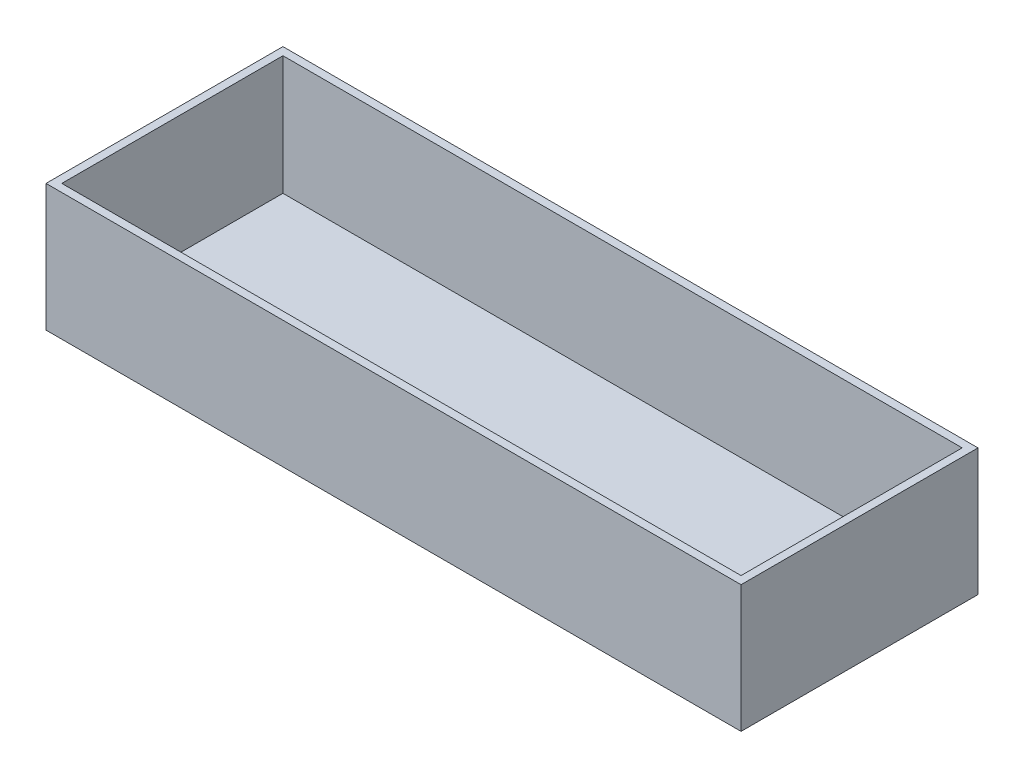
from build123d import *

# Parameters (mm, degrees)
SKETCH1_W           = 279.4
SKETCH1_H           = 95.25
BOSS_EXTRUDE1_DEPTH = 3.175
SKETCH2_W           = 279.4
SKETCH2_H           = 95.25
SKETCH2_W_2         = 273.05
SKETCH2_H_2         = 88.9
BOSS_EXTRUDE2_DEPTH = 47.9044


with BuildPart() as part:
    # Sketch1 → Boss-Extrude1 (new body)
    with BuildSketch(Plane(origin=(0, 0, 0), x_dir=(1, 0, 0), z_dir=(0, 1, 0))):
        Rectangle(SKETCH1_W, SKETCH1_H)
    extrude(amount=BOSS_EXTRUDE1_DEPTH)

    # Sketch2 → Boss-Extrude2 (add)
    with BuildSketch(Plane(origin=(0, 3.175, 0), x_dir=(1, 0, 0), z_dir=(0, 1, 0))):
        Rectangle(SKETCH2_W, SKETCH2_H)
        Rectangle(SKETCH2_W_2, SKETCH2_H_2, mode=Mode.SUBTRACT)
    extrude(amount=BOSS_EXTRUDE2_DEPTH)


solid = part.part
